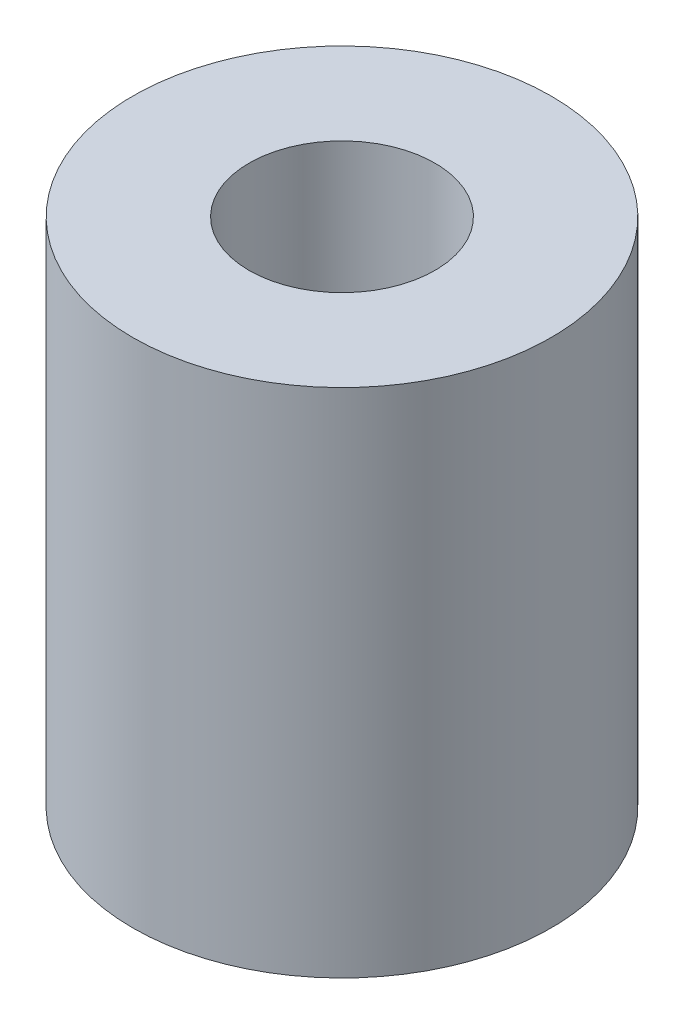
from build123d import *

# Parameters (mm, degrees)
SKETCH1_R           = 36
SKETCH1_R_2         = 16
BOSS_EXTRUDE1_DEPTH = 88


with BuildPart() as part:
    # Sketch1 → Boss-Extrude1 (new body)
    with BuildSketch(Plane(origin=(0, 0, 0), x_dir=(1, 0, 0), z_dir=(0, 1, 0))):
        Circle(SKETCH1_R)
        Circle(SKETCH1_R_2, mode=Mode.SUBTRACT)
    extrude(amount=BOSS_EXTRUDE1_DEPTH)


solid = part.part
